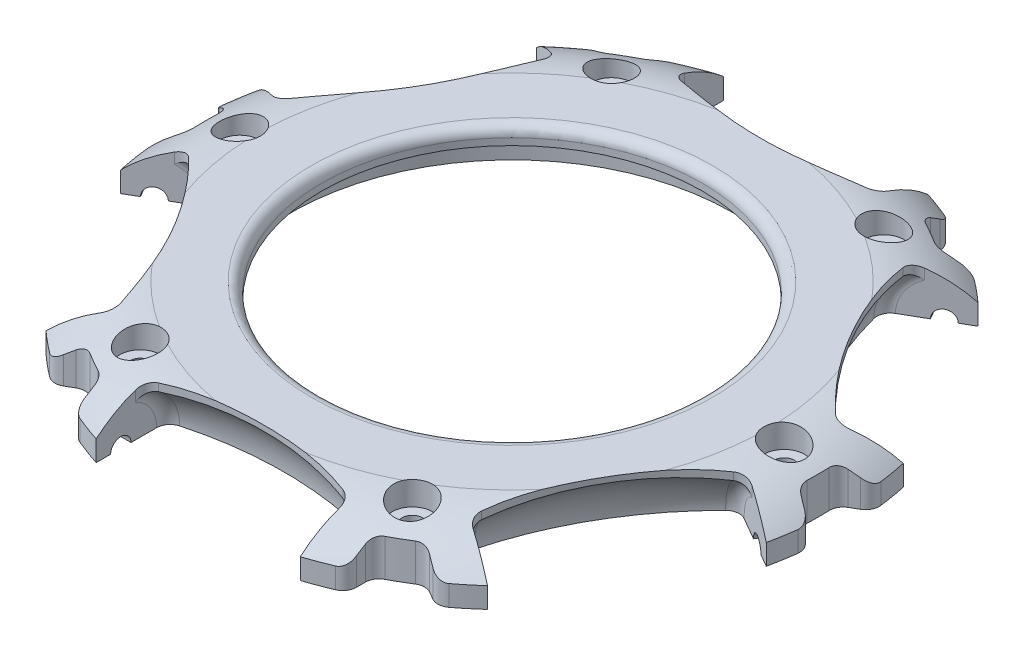
from build123d import *

# Parameters (mm, degrees)
SKETCH2_R           = 50
BOSS_EXTRUDE1_DEPTH = 7.5
CUT_EXTRUDE2_DEPTH  = 7.5
SKETCH5_R           = 1.5
CUT_EXTRUDE3_DEPTH  = 18
CIRPATTERN1_COUNT   = 6
CUT_EXTRUDE4_START  = -7.5
SKETCH6_R           = 50
CUT_EXTRUDE4_DEPTH  = 7.5
SKETCH8_R           = 32.5
CUT_EXTRUDE5_DEPTH  = 5
SKETCH9_R           = 1.5
CUT_EXTRUDE6_DEPTH  = 7.5
SKETCH10_R          = 3
CUT_EXTRUDE7_DEPTH  = 3.5
CIRPATTERN2_COUNT   = 6
FILLET1_R           = 2
FILLET2_R           = 2
FILLET3_R           = 2
CUT_EXTRUDE8_REACH  = 4.5
SKETCH12_R          = 28
FILLET4_R           = 1.5


with BuildPart() as part:
    # Sketch2 → Boss-Extrude1 (new body)
    with BuildSketch(Plane(origin=(0, 0, 0), x_dir=(1, 0, 0), z_dir=(0, 1, 0))):
        Circle(SKETCH2_R)
    extrude(amount=BOSS_EXTRUDE1_DEPTH)

    # Sketch3 → Cut-Revolve1 (revolve, cut)
    with BuildSketch(Plane(origin=(0, 0, 0), x_dir=(1, 0, 0), z_dir=(0, 1, 0))):
        with BuildLine():
            Line((-15, -42.5), (15, -42.5))
            Line((15, -42.5), (15, -35.732870999))
            ThreePointArc((15, -35.732870999), (0, -33.5), (-15, -35.732870999))
            Line((-15, -35.732870999), (-15, -42.5))
        make_face()
    cut_revolve1 = revolve(axis=Axis((-20.180044591, 0, 42.5), (1, 0, 0)), mode=Mode.SUBTRACT)

    # Sketch4 → Cut-Extrude2 (cut)
    with BuildSketch(Plane(origin=(0, 0, 0), x_dir=(1, 0, 0), z_dir=(0, 1, 0))):
        with BuildLine():
            Line((15, -38.877879494), (15, -47.696960071))
            ThreePointArc((15, -47.696960071), (0, -50), (-15, -47.696960071))
            Line((-15, -47.696960071), (-15, -38.877879494))
            ThreePointArc((-15, -38.877879494), (0, -36.5), (15, -38.877879494))
        make_face()
    cut_extrude2 = extrude(amount=CUT_EXTRUDE2_DEPTH, mode=Mode.SUBTRACT)

    # Sketch5 → Cut-Extrude3 (cut, symmetric)
    with BuildSketch(Plane(origin=(0, 0, 0), x_dir=(0, 0, -1), z_dir=(1, 0, 0))):
        with Locations((-42.5, 0)):
            Circle(SKETCH5_R)
    cut_extrude3 = extrude(amount=CUT_EXTRUDE3_DEPTH, both=True, mode=Mode.SUBTRACT)

    # CirPattern1: Cut-Revolve1, Cut-Extrude2, Cut-Extrude3 ×6 about axis
    cirpattern1_axis = Axis((0, 0, 0), (0, 1, 0))
    for i in range(1, CIRPATTERN1_COUNT):
        add(cut_revolve1.rotate(cirpattern1_axis, i * 360 / CIRPATTERN1_COUNT), mode=Mode.SUBTRACT)
        add(cut_extrude2.rotate(cirpattern1_axis, i * 360 / CIRPATTERN1_COUNT), mode=Mode.SUBTRACT)
        add(cut_extrude3.rotate(cirpattern1_axis, i * 360 / CIRPATTERN1_COUNT), mode=Mode.SUBTRACT)

    # Sketch6 → Cut-Extrude4 (cut)
    with BuildSketch(Plane.XZ.offset(CUT_EXTRUDE4_START)):
        Circle(SKETCH6_R)
        with BuildLine():
            Line((-28.264703056, 39.412644686), (-24.910600109, 37.476152446))
            ThreePointArc((-24.910600109, 37.476152446), (-22.5, 38.97114317), (-20, 40.311288741))
            Line((-20, 40.311288741), (-20, 44.18427322))
            ThreePointArc((-20, 44.18427322), (0, 48.5), (20, 44.18427322))
            Line((20, 44.18427322), (20, 40.311288741))
            ThreePointArc((20, 40.311288741), (22.5, 38.97114317), (24.910600109, 37.476152446))
            Line((24.910600109, 37.476152446), (28.264703056, 39.412644686))
            ThreePointArc((28.264703056, 39.412644686), (42.002232084, 24.25), (48.264703056, 4.771628534))
            Line((48.264703056, 4.771628534), (44.910600109, 2.835136295))
            ThreePointArc((44.910600109, 2.835136295), (45, 0), (44.910600109, -2.835136295))
            Line((44.910600109, -2.835136295), (48.264703056, -4.771628534))
            ThreePointArc((48.264703056, -4.771628534), (42.002232084, -24.25), (28.264703056, -39.412644686))
            Line((28.264703056, -39.412644686), (24.910600109, -37.476152446))
            ThreePointArc((24.910600109, -37.476152446), (22.5, -38.97114317), (20, -40.311288741))
            Line((20, -40.311288741), (20, -44.18427322))
            ThreePointArc((20, -44.18427322), (0, -48.5), (-20, -44.18427322))
            Line((-20, -44.18427322), (-20, -40.311288741))
            ThreePointArc((-20, -40.311288741), (-22.5, -38.97114317), (-24.910600109, -37.476152446))
            Line((-24.910600109, -37.476152446), (-28.264703056, -39.412644686))
            ThreePointArc((-28.264703056, -39.412644686), (-42.002232084, -24.25), (-48.264703056, -4.771628534))
            Line((-48.264703056, -4.771628534), (-44.910600109, -2.835136295))
            ThreePointArc((-44.910600109, -2.835136295), (-45, 0), (-44.910600109, 2.835136295))
            Line((-44.910600109, 2.835136295), (-48.264703056, 4.771628534))
            ThreePointArc((-48.264703056, 4.771628534), (-42.002232084, 24.25), (-28.264703056, 39.412644686))
        make_face(mode=Mode.SUBTRACT)
    extrude(amount=CUT_EXTRUDE4_DEPTH, mode=Mode.SUBTRACT)

    # Sketch8 → Cut-Extrude5 (cut)
    with BuildSketch(Plane.XZ):
        Circle(SKETCH8_R)
    extrude(amount=-CUT_EXTRUDE5_DEPTH, mode=Mode.SUBTRACT)

    # Sketch9 → Cut-Extrude6 (cut)
    with BuildSketch(Plane.XZ):
        with Locations((40, 0)):
            Circle(SKETCH9_R)
    cut_extrude6 = extrude(amount=-CUT_EXTRUDE6_DEPTH, mode=Mode.SUBTRACT)

    # Sketch10 → Cut-Extrude7 (cut)
    with BuildSketch(Plane(origin=(0, 7.5, 0), x_dir=(1, 0, 0), z_dir=(0, 1, 0))):
        with Locations((40, 0)):
            Circle(SKETCH10_R)
    cut_extrude7 = extrude(amount=-CUT_EXTRUDE7_DEPTH, mode=Mode.SUBTRACT)

    # CirPattern2: Cut-Extrude6, Cut-Extrude7 ×6 about axis
    cirpattern2_axis = Axis((0, 0, 0), (0, 1, 0))
    for i in range(1, CIRPATTERN2_COUNT):
        add(cut_extrude6.rotate(cirpattern2_axis, i * 360 / CIRPATTERN2_COUNT), mode=Mode.SUBTRACT)
        add(cut_extrude7.rotate(cirpattern2_axis, i * 360 / CIRPATTERN2_COUNT), mode=Mode.SUBTRACT)

    # Sketch7 → Cut-Revolve2 (revolve, cut)
    with BuildSketch(Plane.XY):
        with BuildLine():
            Line((-37.542025369, 7.5), (-50, 7.5))
            Line((-50, 7.5), (-50, 1.5))
            add(Edge.make_bspline(
                [(-50, 1.5), (-45.209417465, 6.974008424), (-37.542025369, 7.5)],
                knots=[0, 0, 0, 1, 1, 1], degree=2))
        make_face()
    revolve(axis=Axis((0, 0, 0), (0, 1, 0)), mode=Mode.SUBTRACT)

    # Fillet1
    fillet1_edges = [part.edges().sort_by_distance(p)[0] for p in [
        (-44.910600109, 2.740335666, -2.835136295),
        (-44.910600109, 2.740335666, 2.835136295),
        (-20, 2.740335666, -40.311288741),
        (-24.910600109, 2.740335666, -37.476152446),
        (24.910600109, 2.740335666, -37.476152446),
        (20, 2.740335666, -40.311288741),
        (44.910600109, 2.740335666, 2.835136295),
        (44.910600109, 2.740335666, -2.835136295),
        (24.910600109, 2.740335666, 37.476152446),
        (20, 2.740335666, 40.311288741),
        (-20, 2.740335666, 40.311288741),
        (-24.910600109, 2.740335666, 37.476152446),
    ]]
    fillet(fillet1_edges, radius=FILLET1_R)

    # Fillet2
    fillet2_edges = [part.edges().sort_by_distance(p)[0] for p in [
        (15, 3.262106543, 36.57102911),
        (-15, 3.262106543, 36.57102911),
        (-41.169231287, 6.258280336, 6.44855869),
        (-26.169231287, 6.258280336, 32.429320804),
        (-26.169231287, 6.258280336, -32.429320804),
        (-41.169231287, 6.258280336, -6.44855869),
        (15, 6.258280336, -38.877879494),
        (-15, 6.258280336, -38.877879494),
        (41.169231287, 6.258280336, -6.44855869),
        (26.169231287, 6.258280336, -32.429320804),
        (26.169231287, 6.258280336, 32.429320804),
        (41.169231287, 6.258280336, 6.44855869),
        (-15, 6.258280336, 38.877879494),
        (15, 6.258280336, 38.877879494),
        (39.171440251, 3.262106543, 5.295133498),
        (24.171440251, 3.262106543, 31.275895612),
        (24.171440251, 3.262106543, -31.275895612),
        (39.171440251, 3.262106543, -5.295133498),
        (-15, 3.262106543, -36.57102911),
        (15, 3.262106543, -36.57102911),
        (-39.171440251, 3.262106543, -5.295133498),
        (-24.171440251, 3.262106543, -31.275895612),
        (-24.171440251, 3.262106543, 31.275895612),
        (-39.171440251, 3.262106543, 5.295133498),
    ]]
    fillet(fillet2_edges, radius=FILLET2_R)

    # Fillet3
    fillet3_edges = [part.edges().sort_by_distance(p)[0] for p in [
        (-48.264703056, 1.514573795, 4.771628534),
        (-48.264703056, 1.514573795, -4.771628534),
        (-28.264703056, 1.514573795, -39.412644686),
        (-20, 1.514573795, -44.18427322),
        (20, 1.514573795, -44.18427322),
        (28.264703056, 1.514573795, -39.412644686),
        (48.264703056, 1.514573795, -4.771628534),
        (48.264703056, 1.514573795, 4.771628534),
        (20, 1.514573795, 44.18427322),
        (28.264703056, 1.514573795, 39.412644686),
        (-28.264703056, 1.514573795, 39.412644686),
        (-20, 1.514573795, 44.18427322),
    ]]
    fillet(fillet3_edges, radius=FILLET3_R)

    # Sketch12 → Cut-Extrude8 (cut, up to next)
    with BuildSketch(Plane.XZ.offset(-5), mode=Mode.PRIVATE) as cut_extrude8_sk1:
        Circle(SKETCH12_R)
    cut_extrude8_tool1 = extrude(cut_extrude8_sk1.sketch, amount=-CUT_EXTRUDE8_REACH, mode=Mode.PRIVATE) & part.part
    add(cut_extrude8_tool1.solids().sort_by_distance((0, 5, 0))[0], mode=Mode.SUBTRACT)

    # Fillet4
    fillet4_edges = [part.edges().sort_by_distance(p)[0] for p in [
        (-28, 7.5, 0),
    ]]
    fillet(fillet4_edges, radius=FILLET4_R)


solid = part.part
